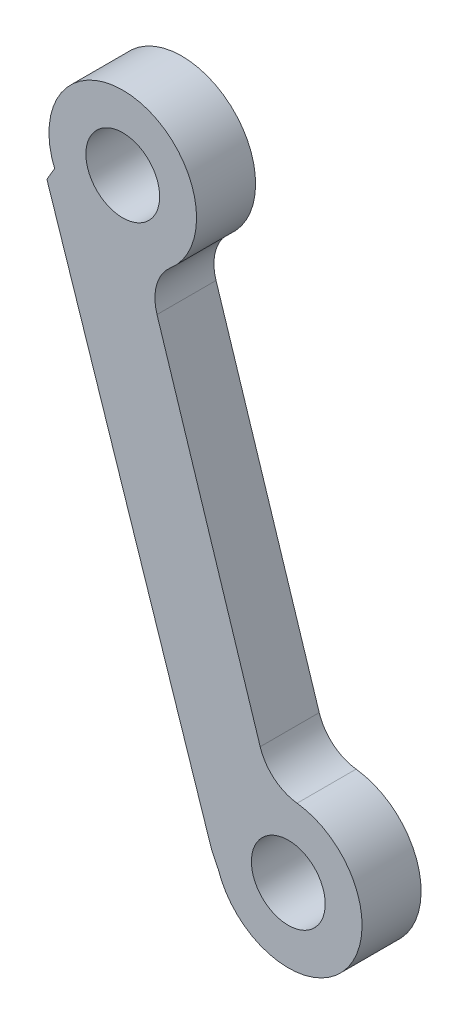
from build123d import *

# Parameters (mm, degrees)
SKETCH1_R           = 2.5
BOSS_EXTRUDE1_DEPTH = 4
FILLET2_R           = 3


with BuildPart() as part:
    # Sketch1 → Boss-Extrude1 (new body)
    with BuildSketch(Plane.XY):
        with BuildLine():
            Line((15.011053362, 49.830662375), (3.838692378, 83.622901822))
            Line((3.838692378, 83.622901822), (4.361186649, 84.509770663))
            ThreePointArc((4.361186649, 84.509770663), (11.04786713, 90.978220722), (10.57313596, 81.686979022))
            Line((10.57313596, 81.686979022), (18.898131325, 55.650415498))
            Line((18.898131325, 55.650415498), (18.969275223, 55.368960637))
            ThreePointArc((18.969275223, 55.368960637), (24.583713079, 48.126504338), (15.45509163, 48.928599175))
            Line((15.45509163, 48.928599175), (15.011053362, 49.830662375))
        make_face()
        with Locations((8.979351439, 86.426161535)):
            Circle(SKETCH1_R, mode=Mode.SUBTRACT)
        with Locations((20.194596002, 50.521426317)):
            Circle(SKETCH1_R, mode=Mode.SUBTRACT)
    extrude(amount=BOSS_EXTRUDE1_DEPTH)

    # Fillet2
    fillet2_edges = [part.edges().sort_by_distance(p)[0] for p in [
        (18.969275223, 55.368960637, 2),
        (10.57313596, 81.686979022, 2),
    ]]
    fillet(fillet2_edges, radius=FILLET2_R)


solid = part.part
